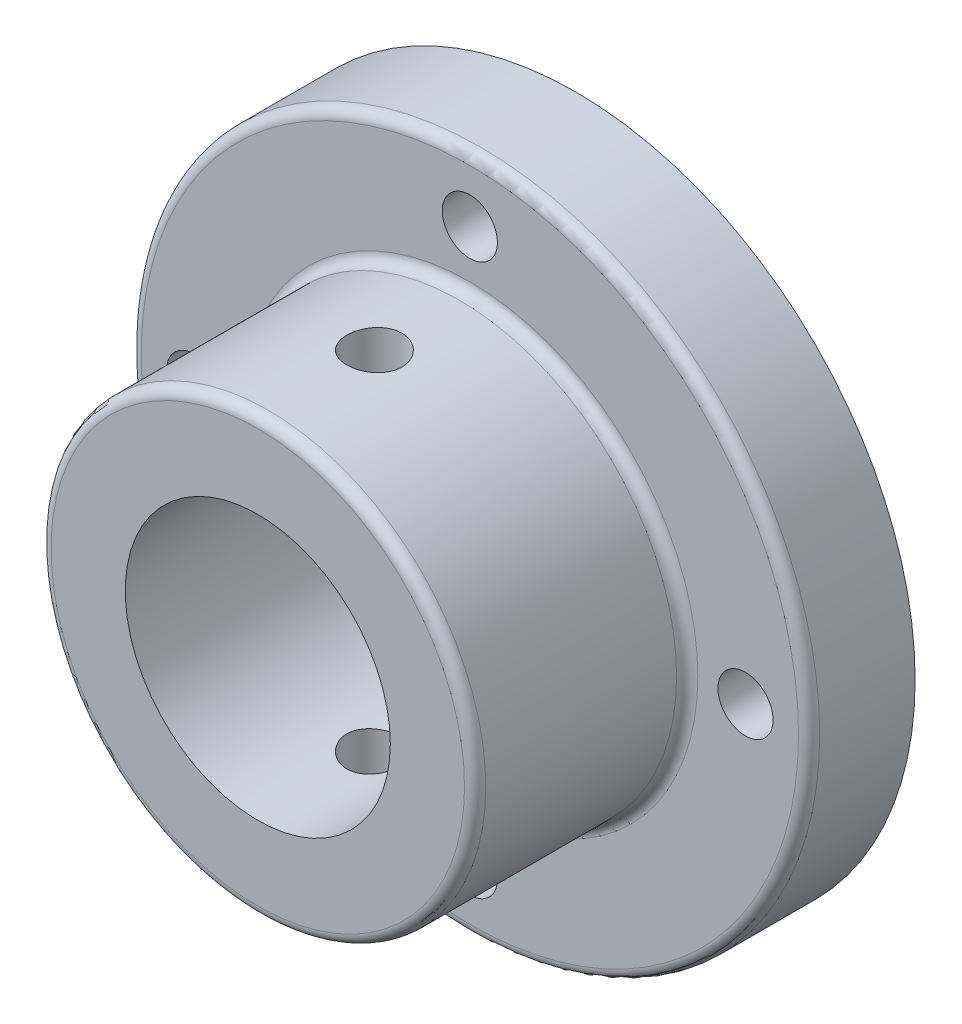
from build123d import *

# Parameters (mm, degrees)
SKETCH1_R               = 16
SKETCH1_R_2             = 1.3
SKETCH1_R_3             = 6.25
BOSS_EXTRUDE1_DEPTH     = 5
SKETCH3_R               = 10.25
SKETCH3_R_2             = 6.25
BOSS_EXTRUDE2_DEPTH     = 15
SKETCH4_R               = 1.3
CUT_EXTRUDE5_DEPTH      = 17
CUT_EXTRUDE5_DEPTH_BACK = 17
FILLET1_R               = 0.5


with BuildPart() as part:
    # Sketch1 → Boss-Extrude1 (new body)
    with BuildSketch(Plane.XY):
        Circle(SKETCH1_R)
        with Locations((0, 13)):
            Circle(SKETCH1_R_2, mode=Mode.SUBTRACT)
        with Locations((13, 0)):
            Circle(SKETCH1_R_2, mode=Mode.SUBTRACT)
        with Locations((0, -13)):
            Circle(SKETCH1_R_2, mode=Mode.SUBTRACT)
        with Locations((-13, 0)):
            Circle(SKETCH1_R_2, mode=Mode.SUBTRACT)
        Circle(SKETCH1_R_3, mode=Mode.SUBTRACT)
    extrude(amount=BOSS_EXTRUDE1_DEPTH)

    # Sketch3 → Boss-Extrude2 (add)
    with BuildSketch(Plane.XY):
        Circle(SKETCH3_R)
        Circle(SKETCH3_R_2, mode=Mode.SUBTRACT)
    extrude(amount=BOSS_EXTRUDE2_DEPTH)

    # Sketch4 → Cut-Extrude5 (cut, two sides)
    with BuildSketch(Plane(origin=(0, 0, 0), x_dir=(1, 0, 0), z_dir=(0, 1, 0))) as cut_extrude5_sk:
        with Locations((0, -9.5)):
            Circle(SKETCH4_R)
    extrude(amount=CUT_EXTRUDE5_DEPTH, mode=Mode.SUBTRACT)
    extrude(cut_extrude5_sk.sketch, amount=-CUT_EXTRUDE5_DEPTH_BACK, mode=Mode.SUBTRACT)

    # Fillet1
    fillet1_edges = [part.edges().sort_by_distance(p)[0] for p in [
        (-10.25, 0, 5),
        (-10.25, 0, 15),
        (-16, 0, 5),
    ]]
    fillet(fillet1_edges, radius=FILLET1_R)


solid = part.part
